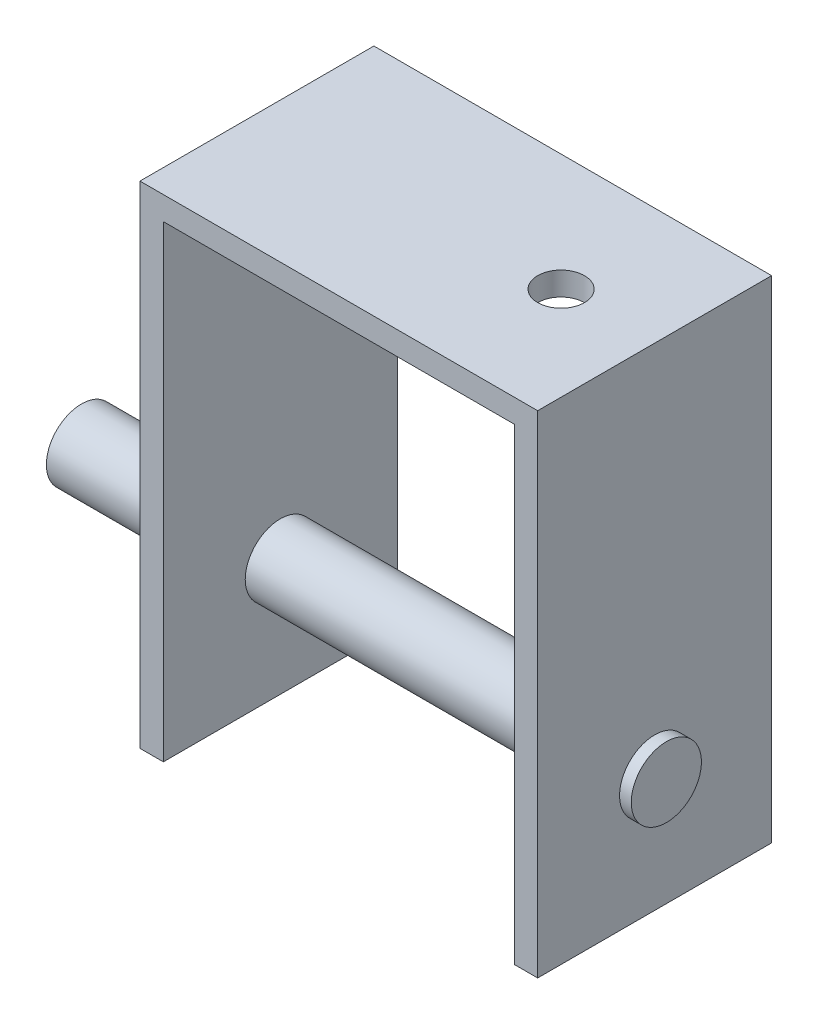
from build123d import *

# Parameters (mm, degrees)
EXTRUDE_1_DEPTH      = 20
SKETCH_3_R           = 3
EXTRUDE_2_DEPTH      = 15
EXTRUDE_2_DEPTH_BACK = 35
SKETCH_4_R           = 2
CUT_EXTRUDE_1_DEPTH  = 2


with BuildPart() as part:
    # 草图1 → 凸台-拉伸1 (new body)
    with BuildSketch(Plane.XY):
        Polygon((-38.9636651, 28.845358616), (-38.9636651, -11.154641384), (-36.9636651, -11.154641384), (-36.9636651, 28.845358616), (-6.9636651, 28.845358616), (-6.9636651, -11.154641384), (-4.9636651, -11.154641384), (-4.9636651, 30.845358616), (-38.9636651, 30.845358616), align=None)
    extrude(amount=EXTRUDE_1_DEPTH)

    # 草图3 → 凸台-拉伸2 (add, two sides)
    with BuildSketch(Plane.ZY.offset(38.9636651)) as extrude_2_sk:
        with Locations((10, -1.154641384)):
            Circle(SKETCH_3_R)
    extrude(amount=EXTRUDE_2_DEPTH)
    extrude(extrude_2_sk.sketch, amount=-EXTRUDE_2_DEPTH_BACK)

    # 草图4 → 切除-拉伸1 (cut)
    with BuildSketch(Plane(origin=(0, 30.845358616, 0), x_dir=(1, 0, 0), z_dir=(0, 1, 0))):
        with Locations((-12.9636651, -10)):
            Circle(SKETCH_4_R)
    extrude(amount=-CUT_EXTRUDE_1_DEPTH, mode=Mode.SUBTRACT)


solid = part.part
